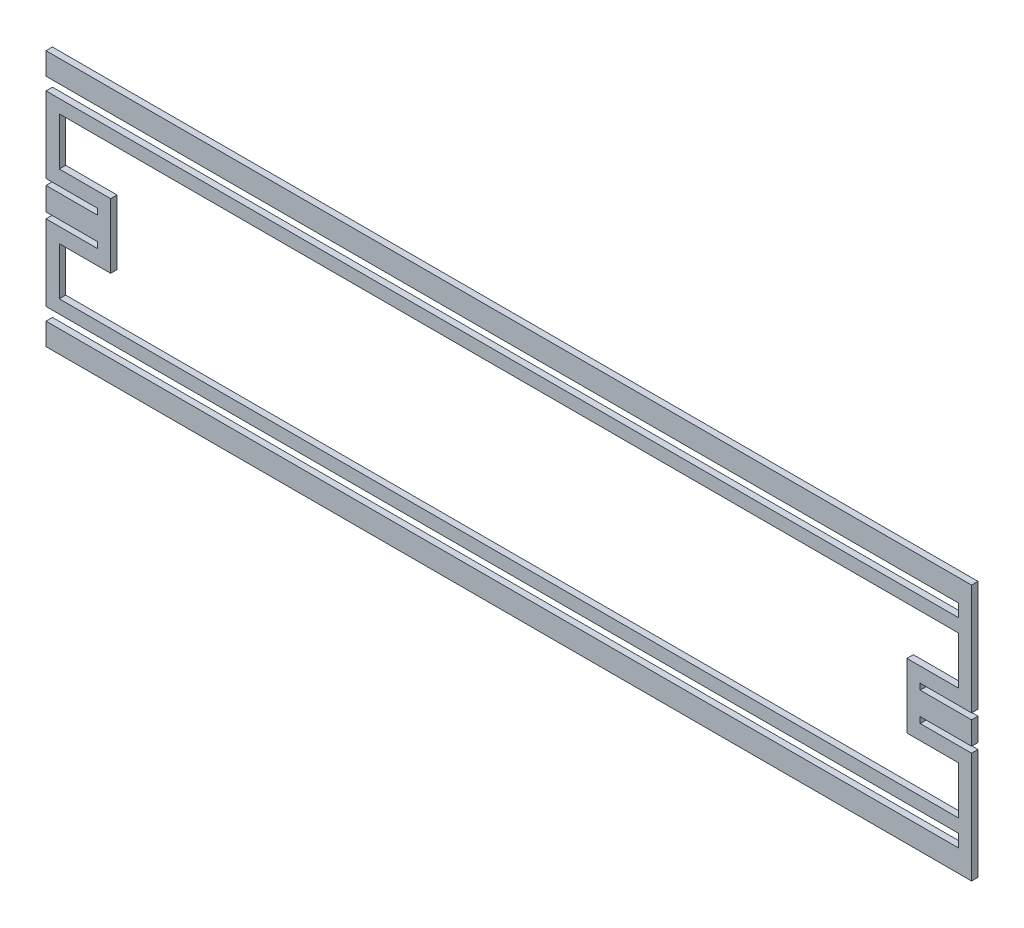
from build123d import *

# Parameters (mm, degrees)
BOSS_EXTRUDE1_DEPTH = 3.175


with BuildPart() as part:
    # Sketch1 → Boss-Extrude1 (new body)
    with BuildSketch(Plane.XY):
        Polygon((-203.3016, -8.62965), (-228.7016, -8.62965), (-228.7016, -46.135925), (222.1484, -46.135925), (222.1484, -52.409725), (-228.7016, -52.409725), (-228.7016, -63.32855), (228.7016, -63.32855), (228.7016, -8.62965), (203.3016, -8.62965), (203.3016, -5.65785), (228.7016, -5.65785), (228.7016, 5.65785), (203.3016, 5.65785), (203.3016, 8.62965), (228.7016, 8.62965), (228.7016, 63.32855), (-228.7016, 63.32855), (-228.7016, 52.409725), (222.1484, 52.409725), (222.1484, 46.135925), (-228.7016, 46.135925), (-228.7016, 8.62965), (-203.3016, 8.62965), (-203.3016, 5.65785), (-228.7016, 5.65785), (-228.7016, -5.65785), (-203.3016, -5.65785), align=None)
        Polygon((222.1484, -39.582725), (222.1484, -15.9766), (196.7484, -15.9766), (196.7484, 15.9766), (222.1484, 15.9766), (222.1484, 39.582725), (-222.1484, 39.582725), (-222.1484, 15.9766), (-196.7484, 15.9766), (-196.7484, -15.9766), (-222.1484, -15.9766), (-222.1484, -39.582725), align=None, mode=Mode.SUBTRACT)
    extrude(amount=BOSS_EXTRUDE1_DEPTH)


solid = part.part
